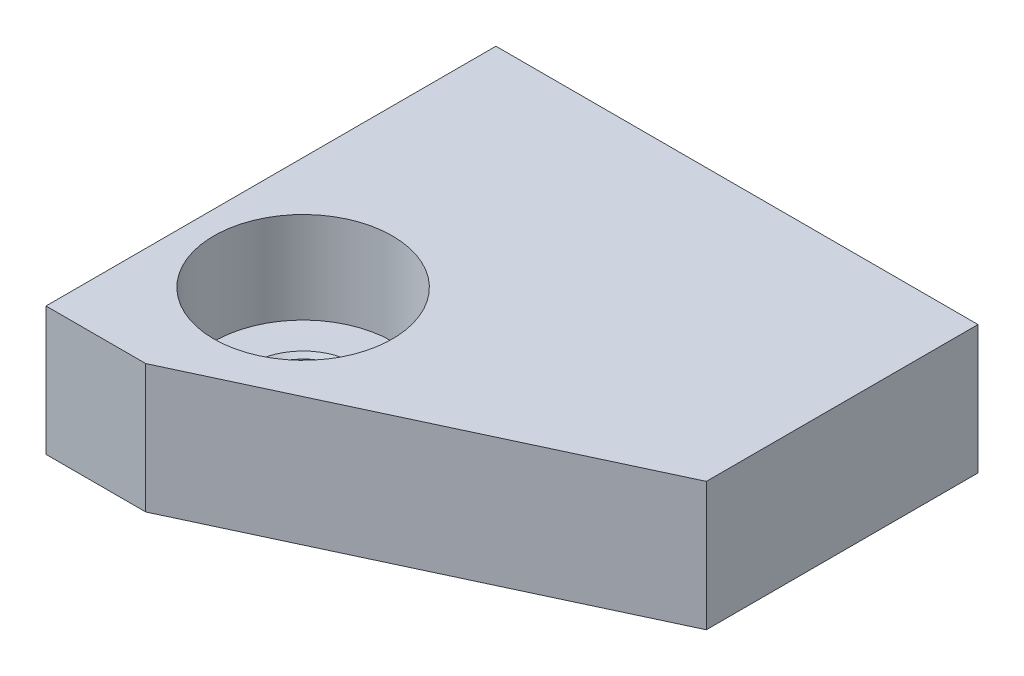
from build123d import *

# Parameters (mm, degrees)
EXTRUDE_1_DEPTH = 4


with BuildPart() as part:
    # Эскиз1 → Бобышка-Вытянуть1 (new body)
    with BuildSketch(Plane(origin=(0, 0, 0), x_dir=(1, 0, 0), z_dir=(0, 1, 0))):
        Polygon((0, 0), (0, -14), (3.103725277, -14), (15, -8.452675993), (15, 0), align=None)
    extrude(amount=EXTRUDE_1_DEPTH)

    # Эскиз2 → Цековка для  винта с внутренним шестигранником #41 (revolve, cut)
    with BuildSketch(Plane(origin=(3.5, 4, 9.5), x_dir=(0, 0, 1), z_dir=(1, 0, 0))):
        Polygon((0, 0), (0, 4), (1.6002, 4), (1.4732, 3.873), (1.4732, 2.9718), (1.6002, 2.8448), (2.77876, 2.8448), (2.77876, 0), align=None)
    revolve(axis=Axis((3.5, 10.35, 9.5), (0, -1, 0)), mode=Mode.SUBTRACT)


solid = part.part
